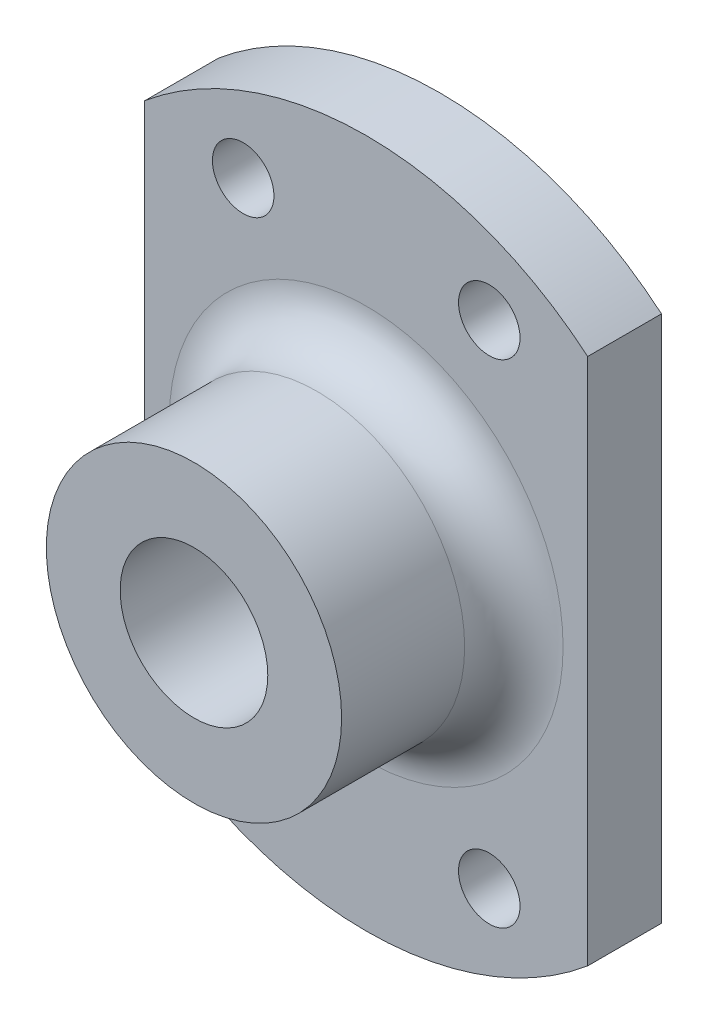
from build123d import *

# Parameters (mm, degrees)
SKETCH1_R               = 3
SKETCH1_R_2             = 1.25
MAIN_DEPTH              = 3
SKETCH2_R               = 6
SKETCH2_R_2             = 3
LINEARBALLSUPPORT_DEPTH = 7
FILLET1_R               = 2


with BuildPart() as part:
    # Sketch1 → Main (new body)
    with BuildSketch(Plane.XY):
        with BuildLine():
            Line((-9, 10.723805295), (-9, -10.723805295))
            ThreePointArc((-9, -10.723805295), (0, -14), (9, -10.723805295))
            Line((9, -10.723805295), (9, 10.723805295))
            ThreePointArc((9, 10.723805295), (0, 14), (-9, 10.723805295))
        make_face()
        Circle(SKETCH1_R, mode=Mode.SUBTRACT)
        with Locations((-5, 10)):
            Circle(SKETCH1_R_2, mode=Mode.SUBTRACT)
        with Locations((5, 10)):
            Circle(SKETCH1_R_2, mode=Mode.SUBTRACT)
        with Locations((-5, -10)):
            Circle(SKETCH1_R_2, mode=Mode.SUBTRACT)
        with Locations((5, -10)):
            Circle(SKETCH1_R_2, mode=Mode.SUBTRACT)
    extrude(amount=MAIN_DEPTH)

    # Sketch2 → LinearBallSupport (add)
    with BuildSketch(Plane.XY.offset(3)):
        Circle(SKETCH2_R)
        Circle(SKETCH2_R_2, mode=Mode.SUBTRACT)
    extrude(amount=LINEARBALLSUPPORT_DEPTH)

    # Fillet1
    fillet1_edges = [part.edges().sort_by_distance(p)[0] for p in [
        (-6, 0, 3),
    ]]
    fillet(fillet1_edges, radius=FILLET1_R)


solid = part.part
